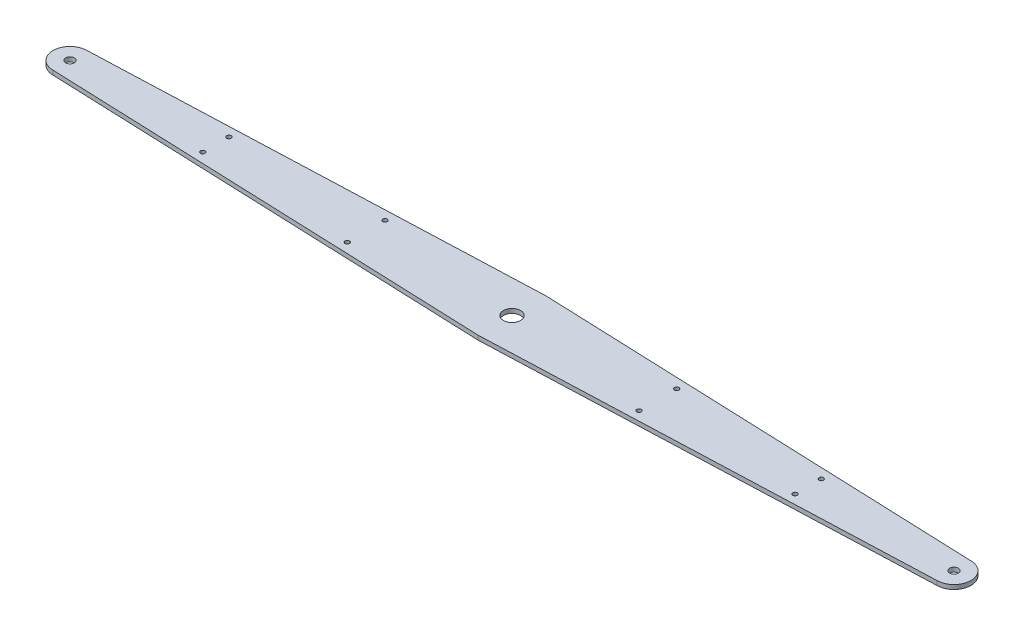
from build123d import *

# Parameters (mm, degrees)
BOSS_EXTRUDE1_DEPTH = 3.18
SKETCH3_R           = 6.35
SKETCH3_R_2         = 3.175
SKETCH3_R_3         = 1.65
CUT_EXTRUDE1_DEPTH  = 4.18


with BuildPart() as part:
    # Sketch2 → Boss-Extrude1 (new body)
    with BuildSketch(Plane(origin=(0, 0, 0), x_dir=(1, 0, 0), z_dir=(0, 1, 0))):
        with BuildLine():
            Line((-325, 12.5), (0, 25))
            Line((0, 25), (325, 12.5))
            ThreePointArc((325, 12.5), (337.5, 0), (325, -12.5))
            Line((325, -12.5), (0, -25))
            Line((0, -25), (-325, -12.5))
            ThreePointArc((-325, -12.5), (-337.5, 0), (-325, 12.5))
        make_face()
    extrude(amount=BOSS_EXTRUDE1_DEPTH)

    # Sketch3 → Cut-Extrude1 (cut, through all)
    with BuildSketch(Plane(origin=(0, 3.18, 0), x_dir=(1, 0, 0), z_dir=(0, 1, 0))):
        Circle(SKETCH3_R)
        with Locations((-325, 0)):
            Circle(SKETCH3_R_2)
        with Locations((-217.75, 9.625)):
            Circle(SKETCH3_R_3)
        with Locations((-107.25, -13.875)):
            Circle(SKETCH3_R_3)
        with Locations((325, 0)):
            Circle(SKETCH3_R_2)
        with Locations((-107.25, 13.875)):
            Circle(SKETCH3_R_3)
        with Locations((-217.75, -9.625)):
            Circle(SKETCH3_R_3)
        with Locations((107.25, -13.875)):
            Circle(SKETCH3_R_3)
        with Locations((107.25, 13.875)):
            Circle(SKETCH3_R_3)
        with Locations((217.75, -9.625)):
            Circle(SKETCH3_R_3)
        with Locations((217.75, 9.625)):
            Circle(SKETCH3_R_3)
    extrude(amount=-CUT_EXTRUDE1_DEPTH, mode=Mode.SUBTRACT)


solid = part.part
